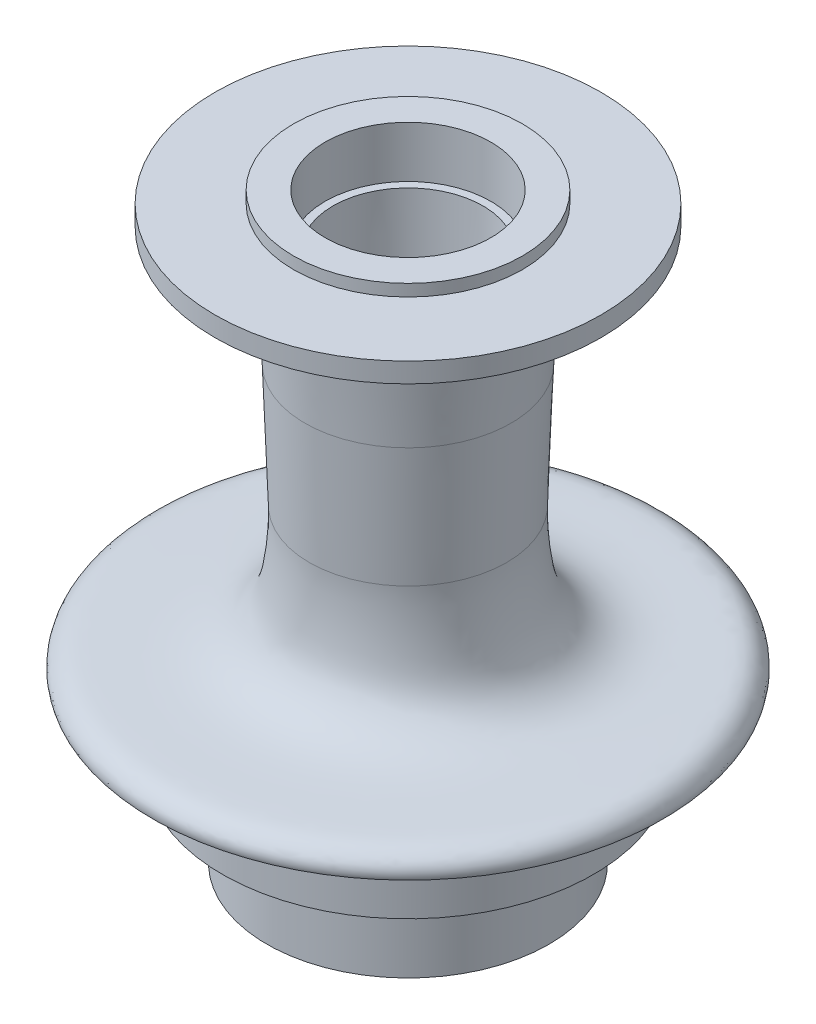
from build123d import *

# Parameters (mm, degrees)
BOSS_EXTRUDE1_REACH = 66.721
SKETCH3_W           = 64.787323871
SKETCH3_H           = 20.939874787


with BuildPart() as part:
    # Sketch1 → Revolve1 (revolve)
    with BuildSketch(Plane.XY):
        with BuildLine():
            Line((19, 74.817317551), (21, 74.817317551))
            Line((21, 74.817317551), (21, 87.817317551))
            Line((21, 87.817317551), (29, 87.817317551))
            Line((29, 87.817317551), (29, 84.817317551))
            Line((29, 84.817317551), (48.884927091, 84.817317551))
            Line((48.884927091, 84.817317551), (48.884927091, 79.817317551))
            Line((48.884927091, 79.817317551), (37.26232647, 79.817317551))
            add(Edge.make_bspline(
                [(37.26232647, 79.817317551), (35.317542772, 79.817317551), (31.576426132, 78.956130843), (28.504834315, 74.722950853), (26.811531328, 69.225059311), (27.023440035, 67.0117878), (26.529376961, 61.457439784), (26.110101007, 49.682029535)],
                knots=[0, 0, 0, 0, 0.027814375, 0.048077406, 0.056130992, 0.108350232, 0.258095951, 0.258095951, 0.258095951, 0.258095951], degree=3))
            Line((26.110101007, 49.682029535), (25.002372474, 18.571354555))
            add(Edge.make_bspline(
                [(64.528129231, -17.987011239), (65.304995671, -15.790991926), (62.495595706, -12.403296178), (55.378812109, -12.037399906), (46.505259928, -12.035031844), (35.990414113, -11.165636172), (27.978614985, -4.711317004), (25.439837988, 5.526983198), (24.863232294, 14.663587636), (25.002372474, 18.571354555)],
                knots=[0, 0, 0, 0, 0.097399991, 0.161218221, 0.32460028, 0.514717464, 0.634012286, 0.770814213, 1, 1, 1, 1], degree=3))
            Line((64.528129231, -17.987011239), (47, -17.987011239))
            Line((47, -17.987011239), (47, -38.859991473))
            Line((47, -38.859991473), (35.75, -38.859991473))
            Line((35.75, -38.859991473), (35.75, -59.79986626))
            Line((35.75, -59.79986626), (33.434340492, -59.79986626))
            Line((33.434340492, -59.79986626), (31.360417848, -39.321612307))
            Line((31.360417848, -39.321612307), (31.360417848, -34.480558786))
            Line((31.360417848, -34.480558786), (17.5, -34.480558786))
            Line((17.5, -34.480558786), (17.5, -23.480558786))
            Line((17.5, -23.480558786), (15.5, -23.480558786))
            Line((15.5, -23.480558786), (19, 74.817317551))
        make_face()
    revolve(axis=Axis((0, 926.027727684, 0), (0, -1, 0)))

    # Sketch3 → Boss-Extrude1 (add, up to next)
    with BuildSketch(Plane(origin=(0, 0, 0), x_dir=(0, 0, -1), z_dir=(1, 0, 0)), mode=Mode.PRIVATE) as boss_extrude1_sk1:
        with Locations((-0.273634545, -49.329928866)):
            Rectangle(SKETCH3_W, SKETCH3_H)
    boss_extrude1_tool1 = extrude(boss_extrude1_sk1.sketch, amount=BOSS_EXTRUDE1_REACH, mode=Mode.PRIVATE) - part.part
    add(boss_extrude1_tool1.solids().sort_by_distance((0, -49.329929, 0.273635))[0])


solid = part.part
